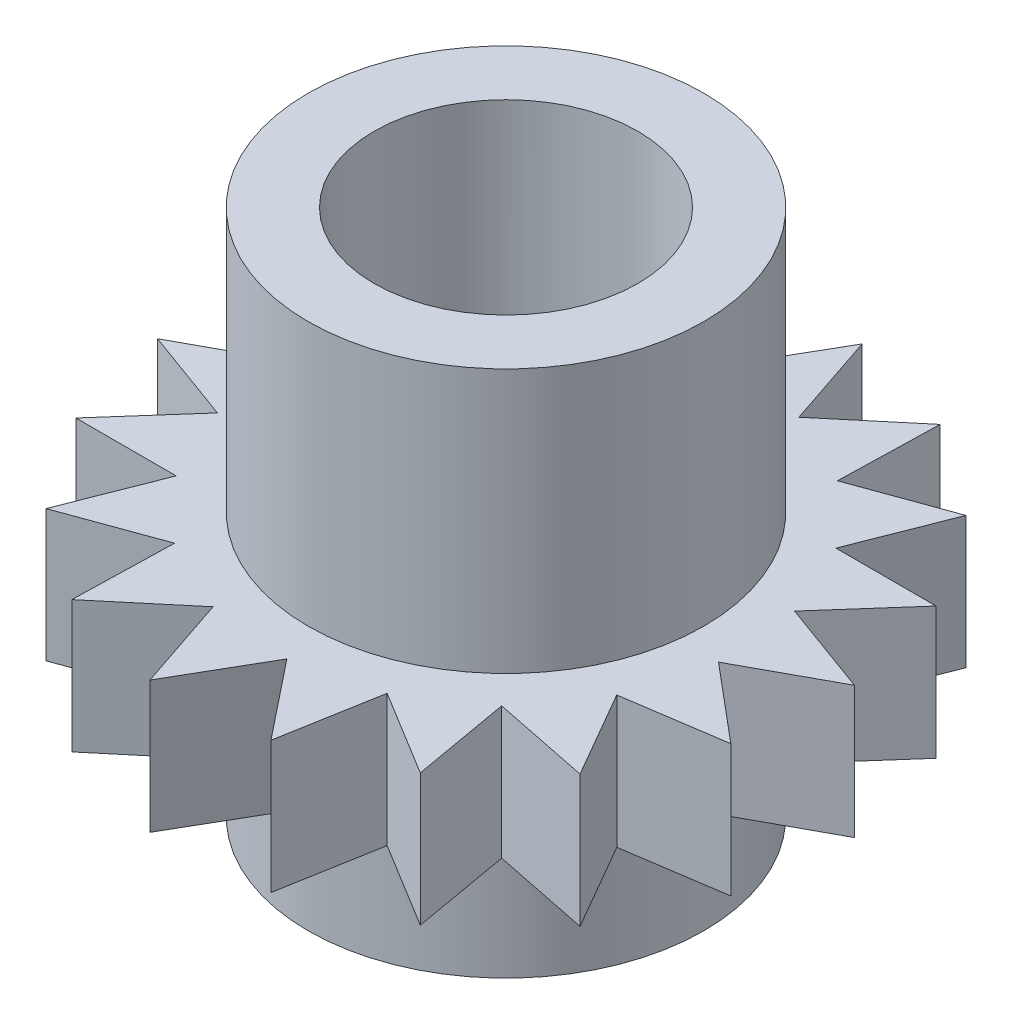
from build123d import *

# Parameters (mm, degrees)
SKETCH1_R           = 9
BOSS_EXTRUDE1_DEPTH = 5
SKETCH2_R           = 7.5
BOSS_EXTRUDE2_DEPTH = 10
SKETCH3_R           = 5
CUT_EXTRUDE1_DEPTH  = 20
SKETCH4_W           = 4
SKETCH4_H           = 2
BOSS_EXTRUDE3_DEPTH = 10


with BuildPart() as part:
    # Sketch1 → Boss-Extrude1 (new body)
    with BuildSketch(Plane(origin=(0, 0, 0), x_dir=(1, 0, 0), z_dir=(0, 1, 0))):
        Circle(SKETCH1_R)
        Polygon((-5.35288104, -11.104144955), (-5.256580304, -7.305365392), (-8.827904062, -8.603689933), (-7.438151841, -5.066941601), (-11.238151569, -5.065502929), (-8.72257249, -2.217369874), (-12.292912138, -0.916341513), (-8.954922165, 0.899649385), (-11.86496608, 3.343344214), (-8.107176067, 3.908157651), (-10.005930004, 7.199773285), (-6.281584886, 6.445284426), (-6.940031098, 10.187803442), (-3.698341861, 8.205014776), (-3.037062017, 11.947034147), (-0.669024226, 8.975099252), (1.232221565, 12.265276214), (2.440987604, 8.6626543), (5.35288104, 11.104144955), (5.256580304, 7.305365392), (8.827904062, 8.603689933), (7.438151841, 5.066941601), (11.238151569, 5.065502929), (8.72257249, 2.217369874), (12.292912138, 0.916341513), (8.954922165, -0.899649385), (11.86496608, -3.343344214), (8.107176067, -3.908157651), (10.005930004, -7.199773285), (6.281584886, -6.445284426), (6.940031098, -10.187803442), (3.698341861, -8.205014776), (3.037062017, -11.947034147), (0.669024226, -8.975099252), (-1.232221565, -12.265276214), (-2.440987604, -8.6626543), align=None)
    extrude(amount=BOSS_EXTRUDE1_DEPTH)

    # Sketch2 → Boss-Extrude2 (add, symmetric)
    with BuildSketch(Plane(origin=(0, 5, 0), x_dir=(1, 0, 0), z_dir=(0, 1, 0))):
        Circle(SKETCH2_R)
    extrude(amount=BOSS_EXTRUDE2_DEPTH, both=True)

    # Sketch3 → Cut-Extrude1 (cut)
    with BuildSketch(Plane(origin=(0, 15, 0), x_dir=(1, 0, 0), z_dir=(0, 1, 0))):
        Circle(SKETCH3_R)
    extrude(amount=-CUT_EXTRUDE1_DEPTH, mode=Mode.SUBTRACT)

    # Sketch4 → Boss-Extrude3 (add)
    with BuildSketch(Plane(origin=(0, 5, 0), x_dir=(1, 0, 0), z_dir=(0, 1, 0))):
        with Locations((0, 5)):
            Rectangle(SKETCH4_W, SKETCH4_H)
    extrude(amount=-BOSS_EXTRUDE3_DEPTH)


solid = part.part
